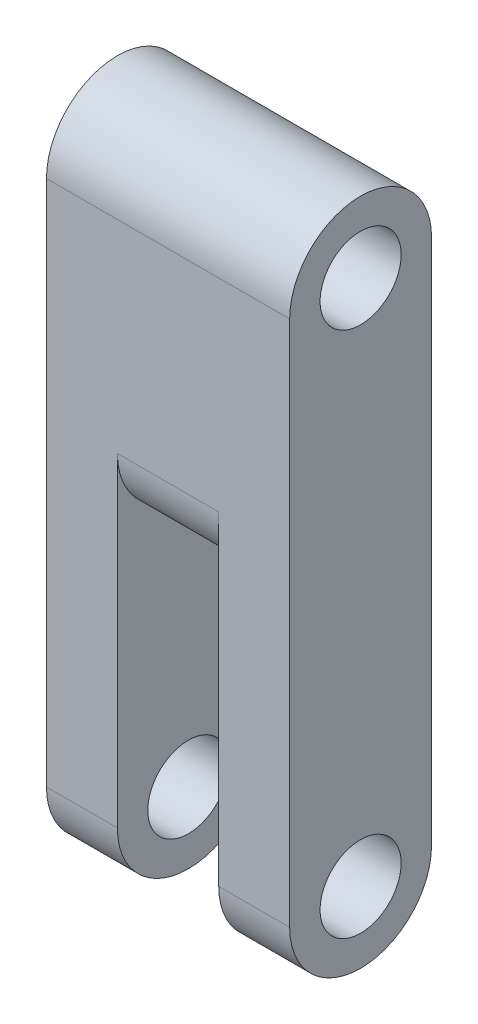
from build123d import *

# Parameters (mm, degrees)
EXTRUDE_1_DEPTH     = 12
SKETCH_2_R          = 2
CUT_EXTRUDE_2_DEPTH = 15
CUT_EXTRUDE_3_DEPTH = 5


with BuildPart() as part:
    # Эскиз1 → Бобышка-Вытянуть1 (new body)
    with BuildSketch(Plane(origin=(0, 0, 0), x_dir=(0, 0, -1), z_dir=(1, 0, 0))):
        with BuildLine():
            Line((0, 0), (0, 26))
            ThreePointArc((0, 26), (3.5, 29.5), (7, 26))
            Line((7, 26), (7, 0))
            ThreePointArc((7, 0), (3.5, -3.5), (0, 0))
        make_face()
    extrude(amount=EXTRUDE_1_DEPTH)

    # Эскиз2 → Вырез-Вытянуть2 (cut)
    with BuildSketch(Plane(origin=(12, 0, 0), x_dir=(0, 0, -1), z_dir=(1, 0, 0))):
        with Locations((3.5, 0)):
            Circle(SKETCH_2_R)
        with Locations((3.5, 26)):
            Circle(SKETCH_2_R)
    extrude(amount=-CUT_EXTRUDE_2_DEPTH, mode=Mode.SUBTRACT)

    # Эскиз3 → Вырез-Вытянуть3 (cut)
    with BuildSketch(Plane(origin=(3.5, 0, 0), x_dir=(0, 0, -1), z_dir=(1, 0, 0))):
        with BuildLine():
            Line((0, 16), (-8.33598626, 16))
            Line((-8.33598626, 16), (-8.33598626, -12.274921498))
            Line((-8.33598626, -12.274921498), (16.66401374, -12.274921498))
            Line((16.66401374, -12.274921498), (16.66401374, 16))
            Line((16.66401374, 16), (7, 16))
            ThreePointArc((7, 16), (3.5, 12.5), (0, 16))
        make_face()
    extrude(amount=CUT_EXTRUDE_3_DEPTH, mode=Mode.SUBTRACT)


solid = part.part
